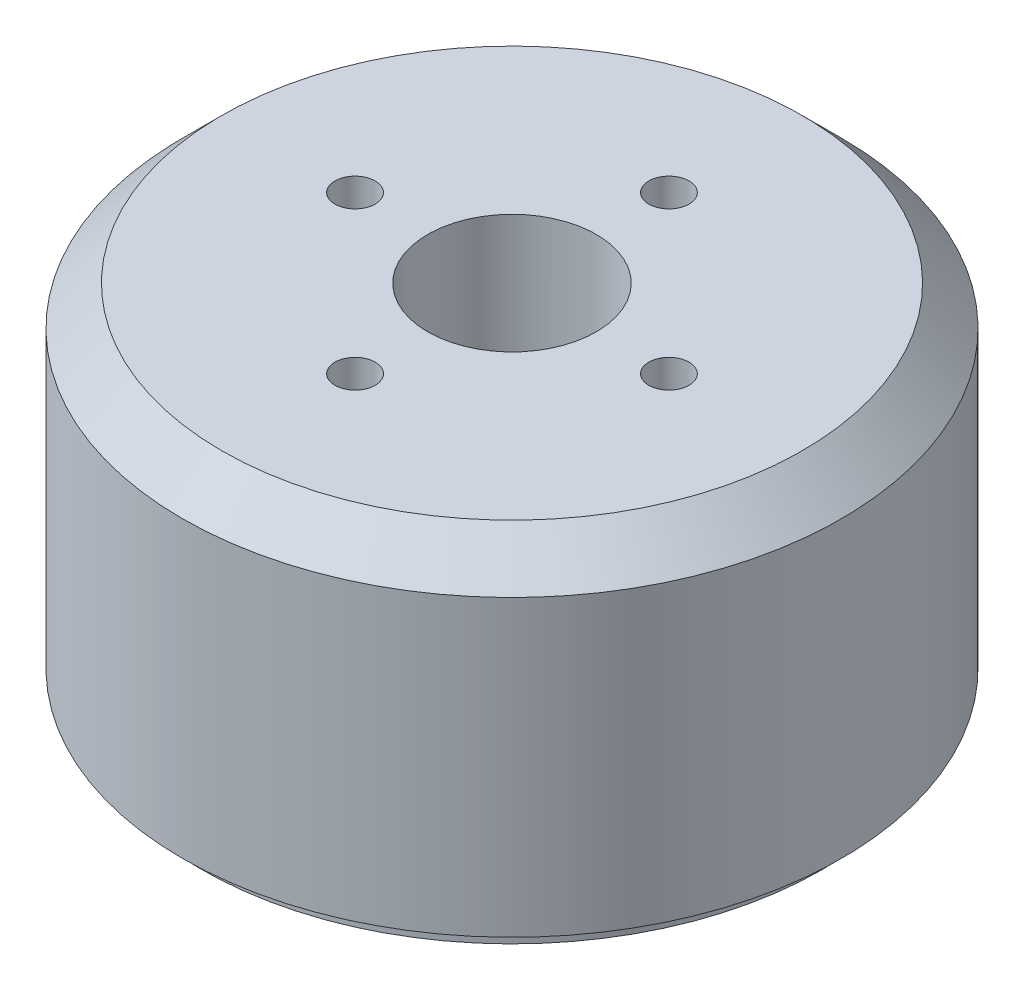
from build123d import *

# Parameters (mm, degrees)
SKETCH_2_R               = 16.8
EXTRUDE_1_DEPTH          = 18
SKETCH_4_R               = 4.3
CUT_EXTRUDE_1_DEPTH      = 30.807381636
CHAMFER_1_SIZE           = 2
PATTERN_CIRCULAR_1_COUNT = 4
SKETCH_8_R               = 5.3
SKETCH_8_R_2             = 4.3
EXTRUDE_1_2_DEPTH        = 2
CUT_EXTRUDE_START        = -0.5
SKETCH_9_R               = 5.3
SKETCH_9_R_2             = 4.8
CUT_EXTRUDE_1_2_DEPTH    = 0.5
SKETCH_10_R              = 16.8
SKETCH_10_R_2            = 15.8
CUT_EXTRUDE_2_DEPTH      = 1
PATTERN_CIRCULAR_2_COUNT = 4


with BuildPart() as part:
    # 草图2 → Extrude 1 (new body)
    with BuildSketch(Plane(origin=(0, 0, 0), x_dir=(1, 0, 0), z_dir=(0, 1, 0))):
        Circle(SKETCH_2_R)
    extrude(amount=EXTRUDE_1_DEPTH)

    # 草图4 → Cut-Extrude 1 (cut, through all)
    with BuildSketch(Plane(origin=(0, 18, 0), x_dir=(1, 0, 0), z_dir=(0, 1, 0))):
        Circle(SKETCH_4_R)
    extrude(amount=-CUT_EXTRUDE_1_DEPTH, mode=Mode.SUBTRACT)

    # 倒角1
    chamfer_1_edges = [part.edges().sort_by_distance(p)[0] for p in [
        (-16.8, 18, 0),
    ]]
    chamfer(chamfer_1_edges, length=CHAMFER_1_SIZE)

    # 草图7 → M2.5 螺纹孔1 (revolve, cut)
    with BuildSketch(Plane(origin=(0, 18, -8), x_dir=(0, 0, 1), z_dir=(1, 0, 0))):
        Polygon((0, 0), (0, 4.615882135), (1.025, 4), (1.025, 0), align=None)
    hole_wizard_m2_5_1 = revolve(axis=Axis((0, 24.35, -8), (0, -1, 0)), mode=Mode.SUBTRACT)

    # 阵列(圆周)1: M2.5 螺纹孔1 ×4 about axis
    pattern_circular_1_axis = Axis((0, 0, 0), (0, 1, 0))
    for i in range(1, PATTERN_CIRCULAR_1_COUNT):
        add(hole_wizard_m2_5_1.rotate(pattern_circular_1_axis, i * 360 / PATTERN_CIRCULAR_1_COUNT), mode=Mode.SUBTRACT)

    # 草图8 → Extrude 1 2 (add)
    with BuildSketch(Plane.XZ):
        Circle(SKETCH_8_R)
        Circle(SKETCH_8_R_2, mode=Mode.SUBTRACT)
    extrude(amount=EXTRUDE_1_2_DEPTH)

    # 草图9 → Cut-Extrude 1 2 (cut)
    with BuildSketch(Plane.XZ.offset(2).offset(CUT_EXTRUDE_START)):
        Circle(SKETCH_9_R)
        Circle(SKETCH_9_R_2, mode=Mode.SUBTRACT)
    extrude(amount=CUT_EXTRUDE_1_2_DEPTH, mode=Mode.SUBTRACT)

    # 草图10 → 切除-拉伸-薄壁2 (cut)
    with BuildSketch(Plane.XZ):
        Circle(SKETCH_10_R)
        Circle(SKETCH_10_R_2, mode=Mode.SUBTRACT)
    extrude(amount=-CUT_EXTRUDE_2_DEPTH, mode=Mode.SUBTRACT)

    # 草图12 → M2.5 螺纹孔2 (revolve, cut)
    with BuildSketch(Plane(origin=(11, 0, 0), x_dir=(0, 0, -1), z_dir=(1, 0, 0))):
        Polygon((0, 0), (0, 4.615882135), (1.025, 4), (1.025, 0), align=None)
    hole_wizard_m2_5_2 = revolve(axis=Axis((11, -6.35, 0), (0, 1, 0)), mode=Mode.SUBTRACT)

    # 阵列(圆周)2: M2.5 螺纹孔2 ×4 about axis
    pattern_circular_2_axis = Axis((0, 0, 0), (0, 1, 0))
    for i in range(1, PATTERN_CIRCULAR_2_COUNT):
        add(hole_wizard_m2_5_2.rotate(pattern_circular_2_axis, i * 360 / PATTERN_CIRCULAR_2_COUNT), mode=Mode.SUBTRACT)


solid = part.part
